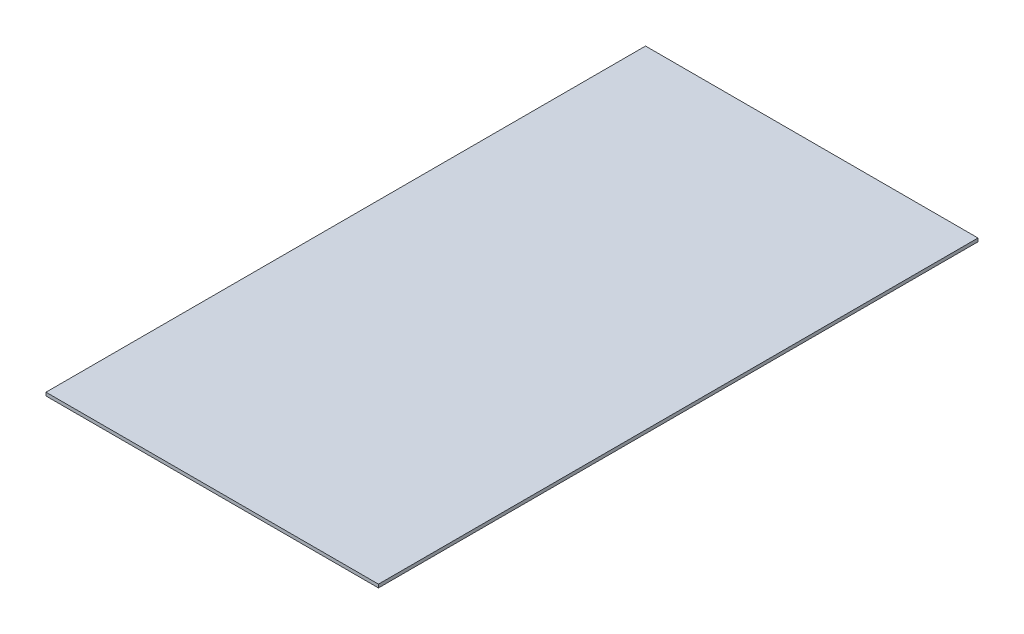
from build123d import *

# Parameters (mm, degrees)
SKETCH1_W           = 300
SKETCH1_H           = 541
BOSS_EXTRUDE1_DEPTH = 3


with BuildPart() as part:
    # Sketch1 → Boss-Extrude1 (new body)
    with BuildSketch(Plane(origin=(0, 0, 0), x_dir=(1, 0, 0), z_dir=(0, 1, 0))):
        Rectangle(SKETCH1_W, SKETCH1_H)
    extrude(amount=BOSS_EXTRUDE1_DEPTH)


solid = part.part
